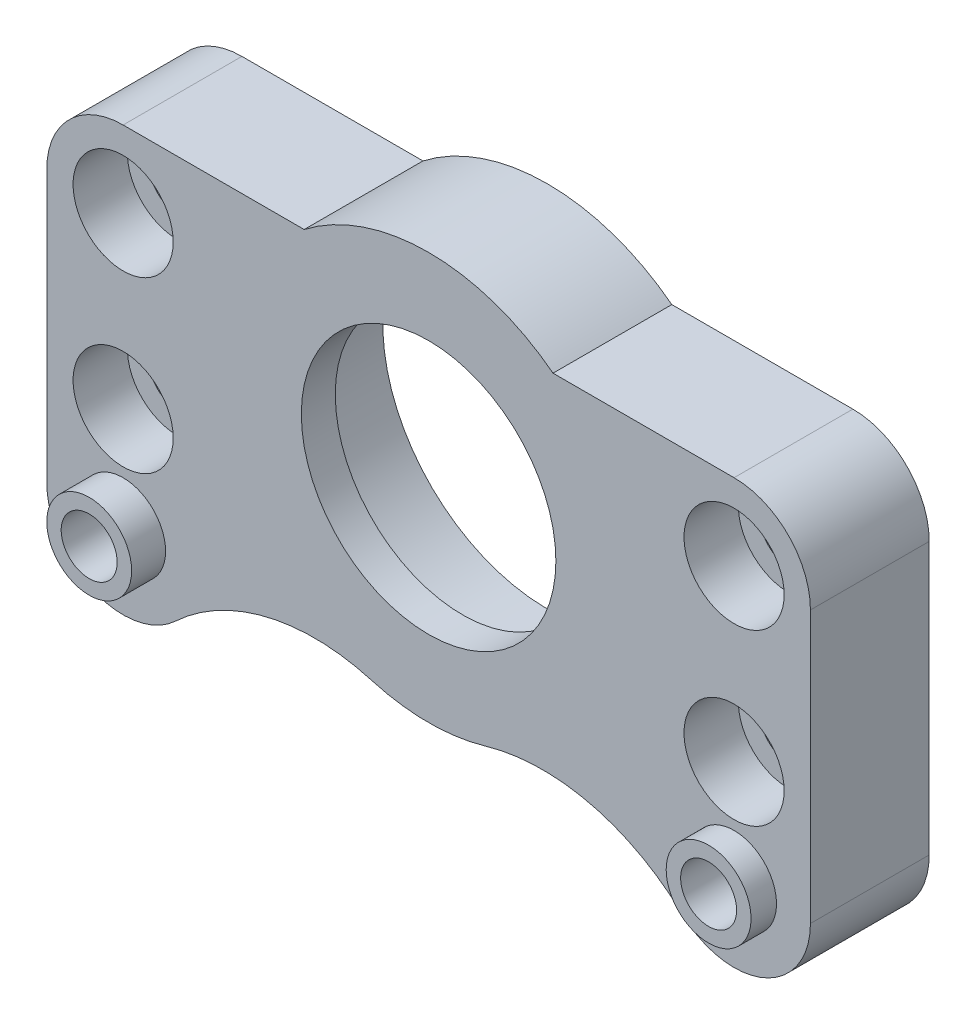
from build123d import *

# Parameters (mm, degrees)
SKETCH2_R           = 1.65
BOSS_EXTRUDE1_DEPTH = 7
SKETCH3_R           = 9.7
CUT_EXTRUDE1_DEPTH  = 5
SKETCH4_R           = 7.5
CUT_EXTRUDE2_DEPTH  = 5
CUT_EXTRUDE3_DEPTH  = 2.5
SKETCH8_R           = 2.95
CUT_EXTRUDE4_DEPTH  = 3.2
SKETCH9_R           = 2.5
SKETCH9_R_2         = 1.65
BOSS_EXTRUDE2_DEPTH = 1.5
MOVE_FACE1_BY       = 0.5


with BuildPart() as part:
    # Sketch2 → Boss-Extrude1 (new body)
    with BuildSketch(Plane.XY):
        with BuildLine():
            Line((-7.331439149, 9.5), (-18, 9.5))
            ThreePointArc((-18, 9.5), (-21.181980515, 8.181980515), (-22.5, 5))
            Line((-22.5, 5), (-22.5, -11))
            ThreePointArc((-22.5, -11), (-19.789453748, -15.128904853), (-14.92317543, -14.283770784))
            ThreePointArc((-14.92317543, -14.283770784), (-9.507484415, -11.369138817), (-3.359154955, -11.520246438))
            ThreePointArc((-3.359154955, -11.520246438), (0, -12), (3.359154955, -11.520246438))
            ThreePointArc((3.359154955, -11.520246438), (9.507484415, -11.369138817), (14.92317543, -14.283770784))
            ThreePointArc((14.92317543, -14.283770784), (19.789453748, -15.128904853), (22.5, -11))
            Line((22.5, -11), (22.5, 5))
            ThreePointArc((22.5, 5), (21.181980515, 8.181980515), (18, 9.5))
            Line((18, 9.5), (7.331439149, 9.5))
            ThreePointArc((7.331439149, 9.5), (0, 12), (-7.331439149, 9.5))
        make_face()
        with Locations((-18, 5)):
            Circle(SKETCH2_R, mode=Mode.SUBTRACT)
        with Locations((-18, -11)):
            Circle(SKETCH2_R, mode=Mode.SUBTRACT)
        with Locations((-18, -5)):
            Circle(SKETCH2_R, mode=Mode.SUBTRACT)
        with Locations(Location((18, -5, 0), (0, 0, 180))):
            Circle(SKETCH2_R, mode=Mode.SUBTRACT)
        with Locations(Location((18, -11, 0), (0, 0, 180))):
            Circle(SKETCH2_R, mode=Mode.SUBTRACT)
        with Locations(Location((18, 5, 0), (0, 0, 180))):
            Circle(SKETCH2_R, mode=Mode.SUBTRACT)
    extrude(amount=BOSS_EXTRUDE1_DEPTH)

    # Sketch3 → Cut-Extrude1 (cut)
    with BuildSketch(Plane.XY):
        Circle(SKETCH3_R)
    extrude(amount=CUT_EXTRUDE1_DEPTH, mode=Mode.SUBTRACT)

    # Sketch4 → Cut-Extrude2 (cut)
    with BuildSketch(Plane(origin=(0, 0, 5), x_dir=(-1, 0, 0), z_dir=(0, 0, -1))):
        Circle(SKETCH4_R)
    extrude(amount=-CUT_EXTRUDE2_DEPTH, mode=Mode.SUBTRACT)

    # Sketch6 → Cut-Extrude3 (cut)
    with BuildSketch(Plane(origin=(0, 0, 0), x_dir=(-1, 0, 0), z_dir=(0, 0, -1))):
        Polygon((-16.325684219, -8.1), (-19.674315781, -8.1), (-21.348631561, -11), (-19.674315781, -13.9), (-16.325684219, -13.9), (-14.651368439, -11), align=None)
        Polygon((14.651368439, -11), (16.325684219, -8.1), (19.674315781, -8.1), (21.348631561, -11), (19.674315781, -13.9), (16.325684219, -13.9), align=None)
    extrude(amount=-CUT_EXTRUDE3_DEPTH, mode=Mode.SUBTRACT)

    # Sketch8 → Cut-Extrude4 (cut)
    with BuildSketch(Plane.XY.offset(7)):
        with Locations((18, -5)):
            Circle(SKETCH8_R)
        with Locations((18, 5)):
            Circle(SKETCH8_R)
        with Locations((-18, 5)):
            Circle(SKETCH8_R)
        with Locations((-18, -5)):
            Circle(SKETCH8_R)
    extrude(amount=-CUT_EXTRUDE4_DEPTH, mode=Mode.SUBTRACT)

    # Sketch9 → Boss-Extrude2 (add)
    with BuildSketch(Plane.XY.offset(7)):
        with Locations((-18, -11)):
            Circle(SKETCH9_R)
        with Locations((-18, -11)):
            Circle(SKETCH9_R_2, mode=Mode.SUBTRACT)
        with Locations(Location((18, -11, 0), (0, 0, 180))):
            Circle(SKETCH9_R)
        with Locations(Location((18, -11, 0), (0, 0, 180))):
            Circle(SKETCH9_R_2, mode=Mode.SUBTRACT)
    extrude(amount=BOSS_EXTRUDE2_DEPTH)

    # Move Face1: a face moved outward by 0.5
    extrude(part.faces().sort_by_distance((-18, -13, 8.5))[0], amount=MOVE_FACE1_BY, dir=(0, 0, 1))


solid = part.part
